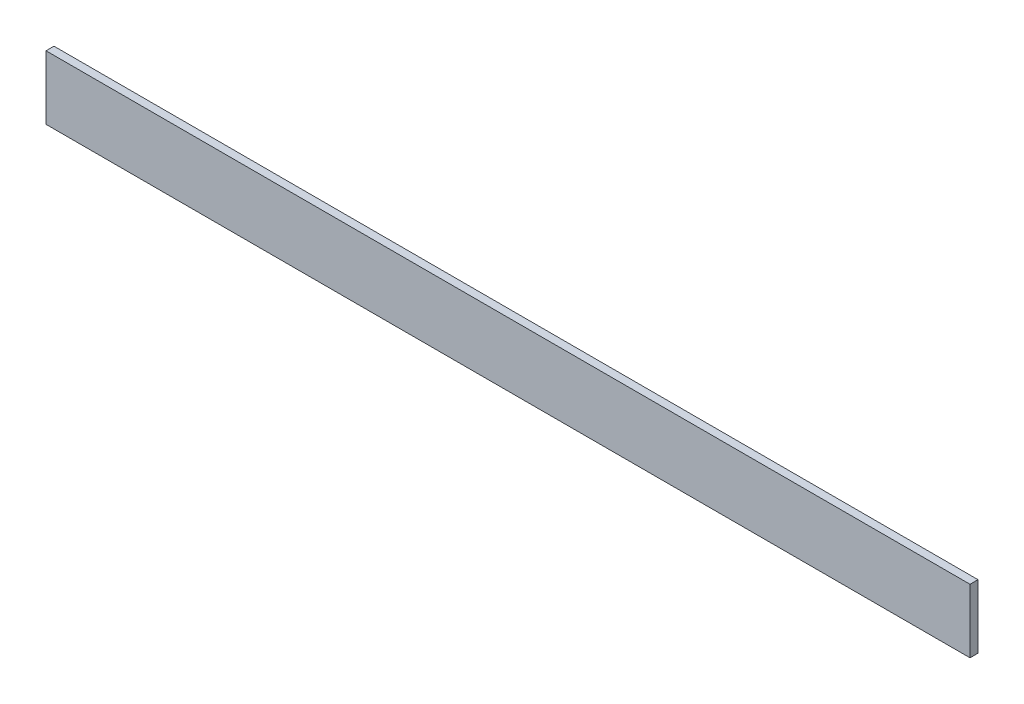
from build123d import *

# Parameters (mm, degrees)
ESQUISSE1_W        = 580
ESQUISSE1_H        = 40
BOSS_EXTRU_1_DEPTH = 5


with BuildPart() as part:
    # Esquisse1 → Boss.-Extru.1 (new body)
    with BuildSketch(Plane.XY):
        Rectangle(ESQUISSE1_W, ESQUISSE1_H)
    extrude(amount=BOSS_EXTRU_1_DEPTH)


solid = part.part
